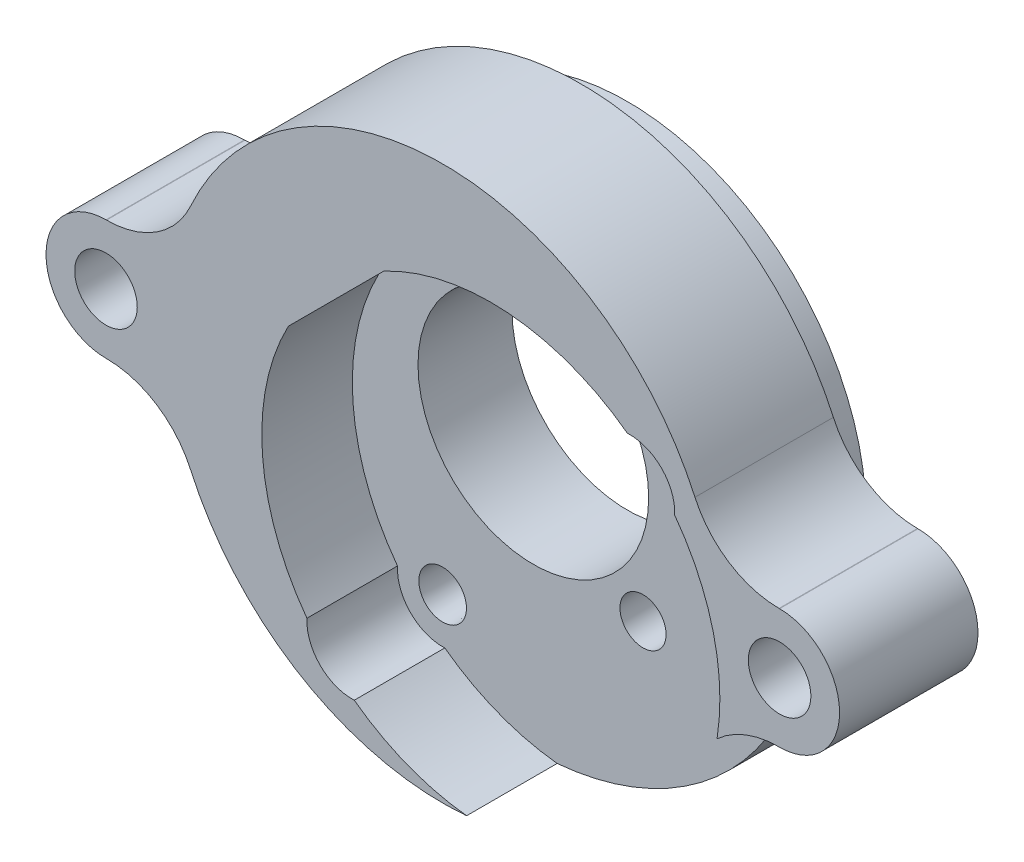
from build123d import *

# Parameters (mm, degrees)
SKETCH1_R                     = 7.9375
BOSS_EXTRUDE1_DEPTH           = 6.35
SKETCH2_R                     = 16.4211
BOSS_EXTRUDE3_DEPTH           = 6.35
BOSS_EXTRUDE3_DEPTH_BACK      = 3.175
F_6_CLEARANCE_HOLE1_D         = 4.3053
F_6_CLEARANCE_HOLE1_DEPTH     = 9.525
F_6_PLASTIC_INSERT_AT_2_COUNT = 2
F_6_PLASTIC_INSERT_AT_2_PITCH = 46.355
BOSS_EXTRUDE4_REACH           = 14.7
SKETCH22_R                    = 16.4211
SKETCH22_R_2                  = 7.9375
CUT_EXTRUDE1_START            = -6.23
CUT_EXTRUDE1_DEPTH            = 6.23
SKETCH24_R                    = 1.5875
CUT_EXTRUDE2_DEPTH            = 13.7
HOLE1_AT_2_COUNT              = 2
HOLE1_AT_2_PITCH              = 27
F_0_CLEARANCE_HOLE1_D         = 1.8542


with BuildPart() as part:
    # Sketch1 → Boss-Extrude1 (new body)
    with BuildSketch(Plane.XY):
        with BuildLine():
            ThreePointArc((16.170566439, -2.8575), (16.4211, 0), (16.170566439, 2.8575))
            ThreePointArc((16.170566439, 2.8575), (0, 16.4211), (-16.170566439, 2.8575))
            ThreePointArc((-16.170566439, 2.8575), (-16.4211, 0), (-16.170566439, -2.8575))
            ThreePointArc((-16.170566439, -2.8575), (0, -16.4211), (16.170566439, -2.8575))
        make_face()
        Circle(SKETCH1_R, mode=Mode.SUBTRACT)
    extrude(amount=BOSS_EXTRUDE1_DEPTH)

    # Sketch2 → Boss-Extrude3 (add, two sides)
    with BuildSketch(Plane.XY.offset(6.35)) as boss_extrude3_sk:
        with BuildLine():
            Line((23.1775, 4.1275), (23.138323054, 4.1275))
            ThreePointArc((23.138323054, 4.1275), (19.696705066, 5.14104372), (17.35374229, 7.858125))
            ThreePointArc((17.35374229, 7.858125), (0, 19.05), (-17.35374229, 7.858125))
            ThreePointArc((-17.35374229, 7.858125), (-19.696705066, 5.14104372), (-23.138323054, 4.1275))
            Line((-23.138323054, 4.1275), (-23.1775, 4.1275))
            ThreePointArc((-23.1775, 4.1275), (-27.305, 0), (-23.1775, -4.1275))
            Line((-23.1775, -4.1275), (-23.138323054, -4.1275))
            ThreePointArc((-23.138323054, -4.1275), (-19.696705066, -5.14104372), (-17.35374229, -7.858125))
            ThreePointArc((-17.35374229, -7.858125), (0, -19.05), (17.35374229, -7.858125))
            ThreePointArc((17.35374229, -7.858125), (19.696705066, -5.14104372), (23.138323054, -4.1275))
            Line((23.138323054, -4.1275), (23.1775, -4.1275))
            ThreePointArc((23.1775, -4.1275), (27.305, 0), (23.1775, 4.1275))
        make_face()
        Circle(SKETCH2_R, mode=Mode.SUBTRACT)
    extrude(amount=BOSS_EXTRUDE3_DEPTH)
    extrude(boss_extrude3_sk.sketch, amount=-BOSS_EXTRUDE3_DEPTH_BACK)

    # #6 Clearance Hole1
    with Locations(Plane(origin=(-22.699598292, 0.104385938, 3.175), x_dir=(-1, 0, 0), z_dir=(0, 0, -1))):
        with Locations((-45.877098292, -0.104385938), (0.477901708, -0.104385938)):
            Hole(F_6_CLEARANCE_HOLE1_D / 2, depth=F_6_CLEARANCE_HOLE1_DEPTH)

    # Sketch5 → #6 Plastic Insert (revolve, cut)
    with BuildSketch(Plane(origin=(23.1775, 0, 3.175), x_dir=(0, 1, 0), z_dir=(1, 0, 0))):
        Polygon((0, 0), (0, 3.81), (2.5273, 3.81), (2.6543, 0), align=None)
    f_6_plastic_insert = revolve(axis=Axis((23.1775, 0, 113.175), (0, 0, -1)), mode=Mode.SUBTRACT)

    # #6 Plastic Insert at 2: #6 Plastic Insert ×2
    with Locations(*[(-i * F_6_PLASTIC_INSERT_AT_2_PITCH, 0, 0) for i in range(1, F_6_PLASTIC_INSERT_AT_2_COUNT)]):
        add(f_6_plastic_insert, mode=Mode.SUBTRACT)

    # Sketch22 → Boss-Extrude4 (add, up to next)
    with BuildSketch(Plane.XY.offset(12.7), mode=Mode.PRIVATE) as boss_extrude4_sk1:
        Circle(SKETCH22_R)
        Circle(SKETCH22_R_2, mode=Mode.SUBTRACT)
    boss_extrude4_tool1 = extrude(boss_extrude4_sk1.sketch, amount=-BOSS_EXTRUDE4_REACH, mode=Mode.PRIVATE) - part.part
    add(boss_extrude4_tool1.solids().sort_by_distance((-15.956641, 0, 12.7))[0])

    # Sketch23 → Cut-Extrude1 (cut)
    with BuildSketch(Plane.XY.offset(12.7).offset(CUT_EXTRUDE1_START)):
        with BuildLine():
            Line((-4.060251152, 10.629391126), (-10.629391126, 4.060251152))
            ThreePointArc((-10.629391126, 4.060251152), (-12.41058312, -4.506273431), (-9.348763248, -12.702812177))
            ThreePointArc((-9.348763248, -12.702812177), (-8.44083665, -15.052079048), (-6.091569778, -15.960005646))
            ThreePointArc((-6.091569778, -15.960005646), (14.451038284, -14.451038284), (15.960005646, 6.091569778))
            ThreePointArc((15.960005646, 6.091569778), (15.052079048, 8.44083665), (12.702812177, 9.348763248))
            ThreePointArc((12.702812177, 9.348763248), (4.506273431, 12.41058312), (-4.060251152, 10.629391126))
        make_face()
    extrude(amount=CUT_EXTRUDE1_DEPTH, mode=Mode.SUBTRACT)

    # Sketch24 → Cut-Extrude2 (cut, through all)
    with BuildSketch(Plane(origin=(0, 0, 0), x_dir=(-1, 0, 0), z_dir=(0, 0, -1))):
        with Locations((-7.548261886, -7.548261886)):
            Circle(SKETCH24_R)
    extrude(amount=-CUT_EXTRUDE2_DEPTH, mode=Mode.SUBTRACT)

    # Sketch26 → Hole1 (revolve, cut)
    with BuildSketch(Plane(origin=(-6.240320347, -12.851562745, 6.47), x_dir=(0, -1, 0), z_dir=(1, 0, 0))):
        Polygon((0, 0), (0, 2.921), (1.4986, 2.921), (1.6383, 0), align=None)
    hole1 = revolve(axis=Axis((-6.240320347, -12.851562745, -103.53), (0, 0, 1)), mode=Mode.SUBTRACT)

    # Hole1 at 2: Hole1 ×2
    with Locations(*[Vector(0.707106781, 0.707106781, 0) * (i * HOLE1_AT_2_PITCH) for i in range(1, HOLE1_AT_2_COUNT)]):
        add(hole1, mode=Mode.SUBTRACT)

    # #0 Clearance Hole1 (through all)
    with Locations(Plane.XY.offset(6.47)):
        with Locations((-6.240320347, -12.851562745), (12.851562745, 6.240320347)):
            Hole(F_0_CLEARANCE_HOLE1_D / 2)


solid = part.part
